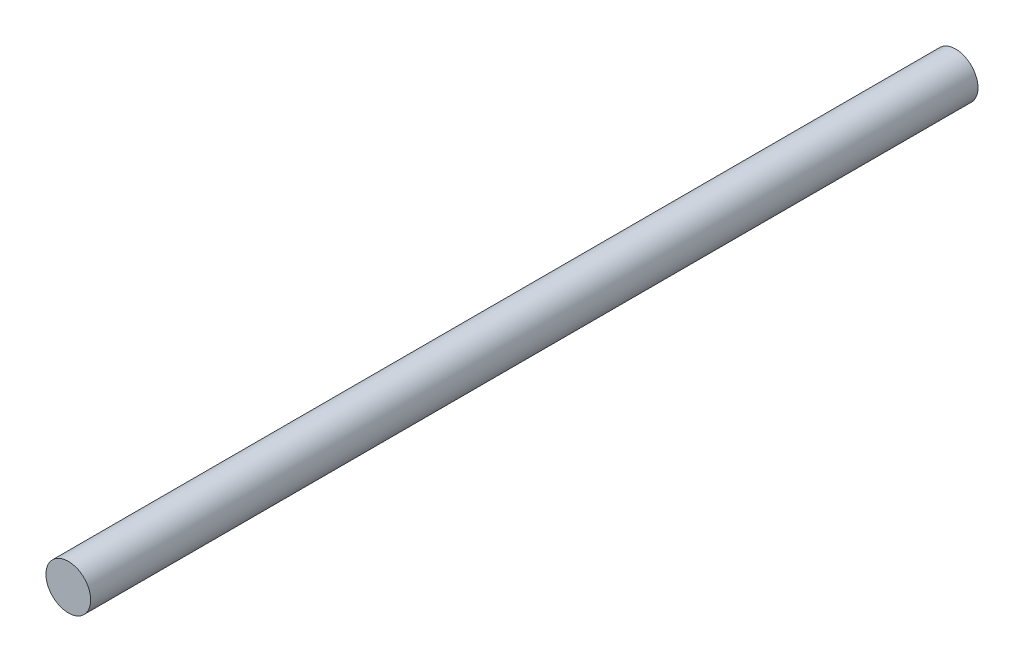
from build123d import *

# Parameters (mm, degrees)
SKETCH1_R           = 3.175
BOSS_EXTRUDE1_DEPTH = 126


with BuildPart() as part:
    # Sketch1 → Boss-Extrude1 (new body)
    with BuildSketch(Plane.XY):
        Circle(SKETCH1_R)
    extrude(amount=BOSS_EXTRUDE1_DEPTH)


solid = part.part
